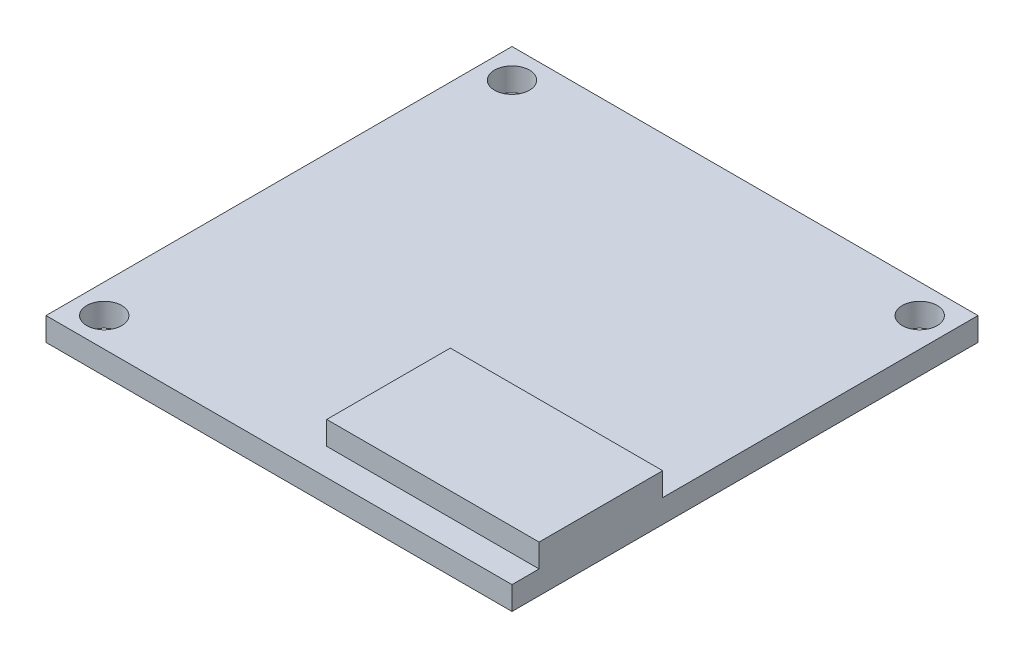
from build123d import *

# Parameters (mm, degrees)
SKETCH1_W           = 40
SKETCH1_H           = 40
BOSS_EXTRUDE1_DEPTH = 2
SKETCH2_R           = 1.5
CUT_EXTRUDE1_DEPTH  = 3
SKETCH3_W           = 18.229825434
SKETCH3_H           = 10.610339614
BOSS_EXTRUDE2_DEPTH = 2


with BuildPart() as part:
    # Sketch1 → Boss-Extrude1 (new body)
    with BuildSketch(Plane(origin=(0, 0, 0), x_dir=(1, 0, 0), z_dir=(0, 1, 0))):
        with Locations((20, 20)):
            Rectangle(SKETCH1_W, SKETCH1_H)
    extrude(amount=BOSS_EXTRUDE1_DEPTH)

    # Sketch2 → Cut-Extrude1 (cut, through all)
    with BuildSketch(Plane(origin=(0, 2, 0), x_dir=(1, 0, 0), z_dir=(0, 1, 0))):
        with Locations((2.5, 37.5)):
            Circle(SKETCH2_R)
        with Locations((37.5, 37.5)):
            Circle(SKETCH2_R)
        with Locations((2.5, 2.5)):
            Circle(SKETCH2_R)
    extrude(amount=-CUT_EXTRUDE1_DEPTH, mode=Mode.SUBTRACT)

    # Sketch3 → Boss-Extrude2 (add)
    with BuildSketch(Plane(origin=(0, 2, 0), x_dir=(1, 0, 0), z_dir=(0, 1, 0))):
        with Locations((30.885087283, 7.630399835)):
            Rectangle(SKETCH3_W, SKETCH3_H)
    extrude(amount=BOSS_EXTRUDE2_DEPTH)


solid = part.part
